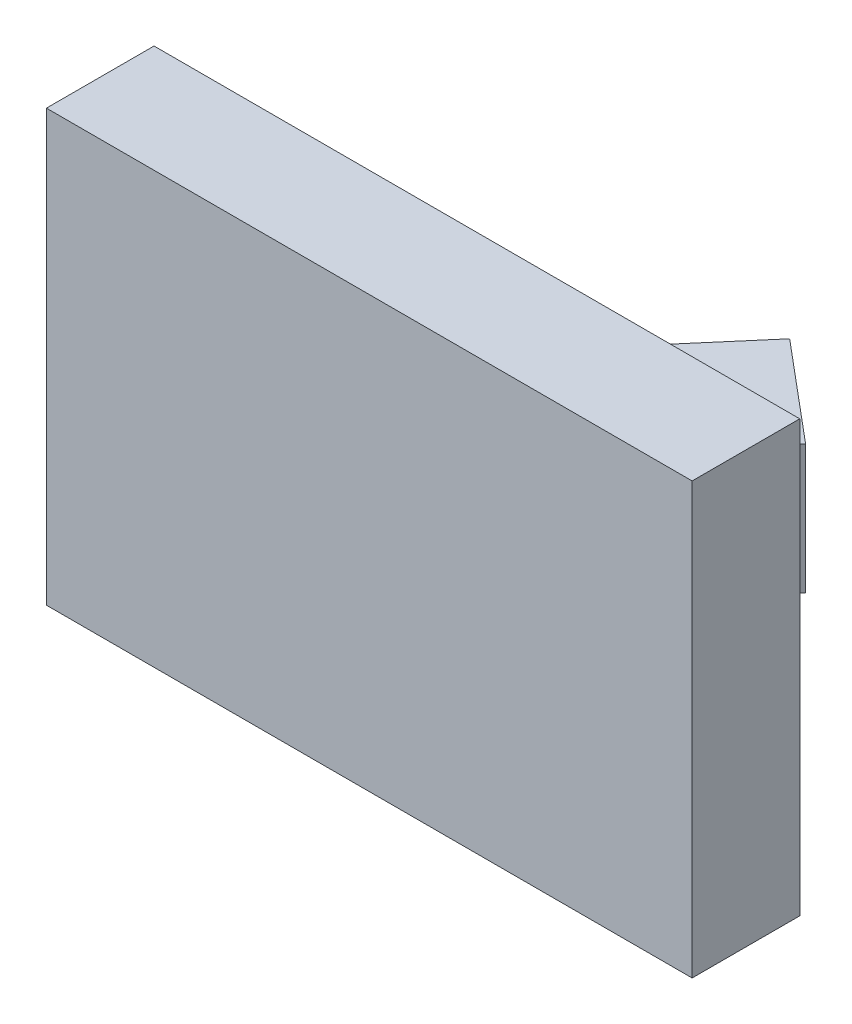
from build123d import *

# Parameters (mm, degrees)
CROQUIS1_W                   = 30
CROQUIS1_H                   = 20
SALIENTE_EXTRUIR1_DEPTH      = 5
SALIENTE_EXTRUIR2_DEPTH      = 3
SALIENTE_EXTRUIR2_DEPTH_BACK = 3
CROQUIS4_R                   = 2.1
CORTAR_EXTRUIR1_DEPTH        = 7


with BuildPart() as part:
    # Croquis1 → Saliente-Extruir1 (new body)
    with BuildSketch(Plane.XY):
        Rectangle(CROQUIS1_W, CROQUIS1_H)
    extrude(amount=SALIENTE_EXTRUIR1_DEPTH)

    # Croquis3 → Saliente-Extruir2 (add, two sides)
    with BuildSketch(Plane(origin=(0, 0, 0), x_dir=(1, 0, 0), z_dir=(0, 1, 0))) as saliente_extruir2_sk:
        Polygon((-4, 0), (4, 0), (9.142300877, 6.128355545), (4.546034219, 9.985081203), align=None)
    extrude(amount=SALIENTE_EXTRUIR2_DEPTH)
    extrude(saliente_extruir2_sk.sketch, amount=-SALIENTE_EXTRUIR2_DEPTH_BACK)

    # Croquis4 → Cortar-Extruir1 (cut)
    with BuildSketch(Plane(origin=(6.795004522, 0, -8.097971051), x_dir=(-0.766044443, 0, -0.64278761), z_dir=(0.64278761, 0, -0.766044443))):
        Circle(CROQUIS4_R)
    extrude(amount=-CORTAR_EXTRUIR1_DEPTH, mode=Mode.SUBTRACT)


solid = part.part
